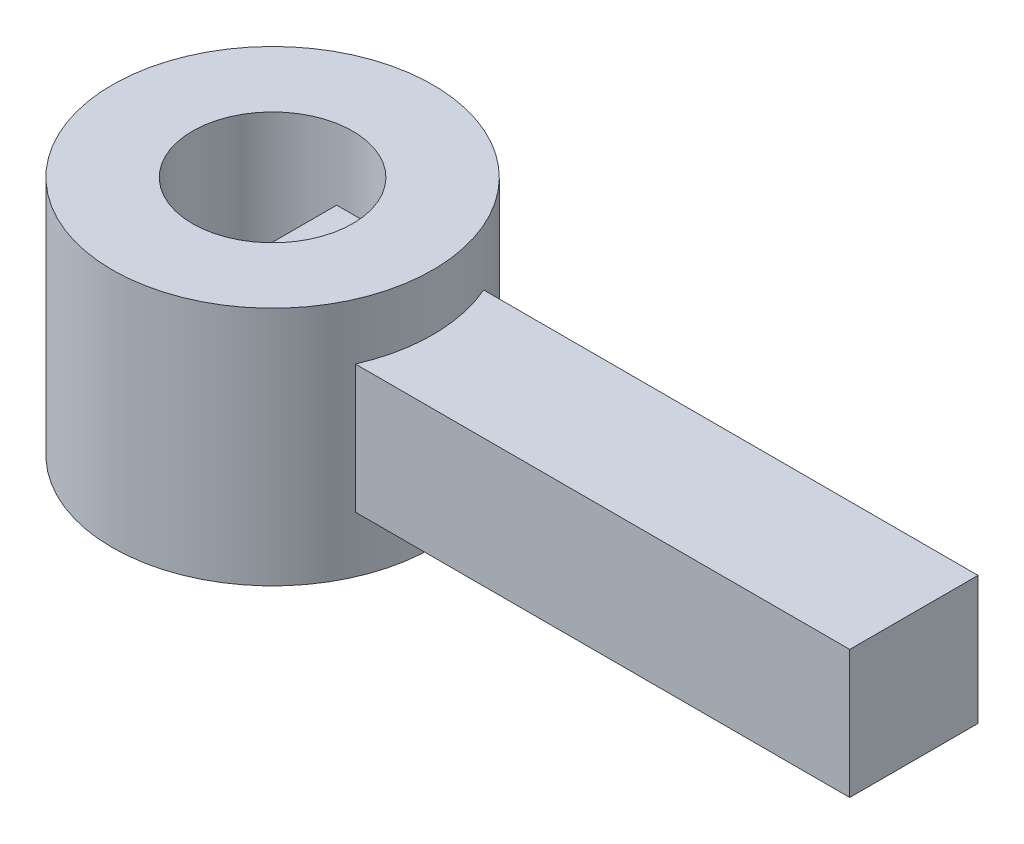
from build123d import *

# Parameters (mm, degrees)
CUT_EXTRUDE1_DEPTH       = 10.898670365
CUT_EXTRUDE1_DEPTH_BACK  = 10.898670365
SKETCH2_R                = 3.175
BOSS_EXTRUDE1_DEPTH      = 4.7625
BOSS_EXTRUDE1_DEPTH_BACK = 4.7625
SKETCH3_R                = 6.35
SKETCH3_R_2              = 3.175
SKETCH4_W                = 5.08
SKETCH4_H                = 5.08
BOSS_EXTRUDE2_DEPTH      = 25.4


with BuildPart() as part:
    # Sketch1 → Revolve1 (revolve)
    with BuildSketch(Plane.XY):
        with BuildLine():
            Line((0, 5.715), (0, -5.715))
            ThreePointArc((0, -5.715), (5.715, 0), (0, 5.715))
        make_face()
    revolve(axis=Axis((0, 5.715, 0), (0, -1, 0)))

    # Sketch2 → Cut-Extrude1 (cut, two sides: drawn at the far end of the back side and taken through both)
    with BuildSketch(Plane(origin=(0, 0, 0), x_dir=(1, 0, 0), z_dir=(0, 1, 0)).offset(-CUT_EXTRUDE1_DEPTH_BACK)):
        Circle(SKETCH2_R)
    extrude(amount=CUT_EXTRUDE1_DEPTH + CUT_EXTRUDE1_DEPTH_BACK, mode=Mode.SUBTRACT)

    # Sketch3 → Boss-Extrude1 (add, two sides: drawn at the far end of the back side and taken through both)
    with BuildSketch(Plane(origin=(0, 0, 0), x_dir=(1, 0, 0), z_dir=(0, 1, 0)).offset(-BOSS_EXTRUDE1_DEPTH_BACK)):
        Circle(SKETCH3_R)
        Circle(SKETCH3_R_2, mode=Mode.SUBTRACT)
    extrude(amount=BOSS_EXTRUDE1_DEPTH + BOSS_EXTRUDE1_DEPTH_BACK)

    # Sketch4 → Boss-Extrude2 (add)
    with BuildSketch(Plane(origin=(0, 0, 0), x_dir=(0, 0, -1), z_dir=(1, 0, 0))):
        Rectangle(SKETCH4_W, SKETCH4_H)
    extrude(amount=BOSS_EXTRUDE2_DEPTH)


solid = part.part
